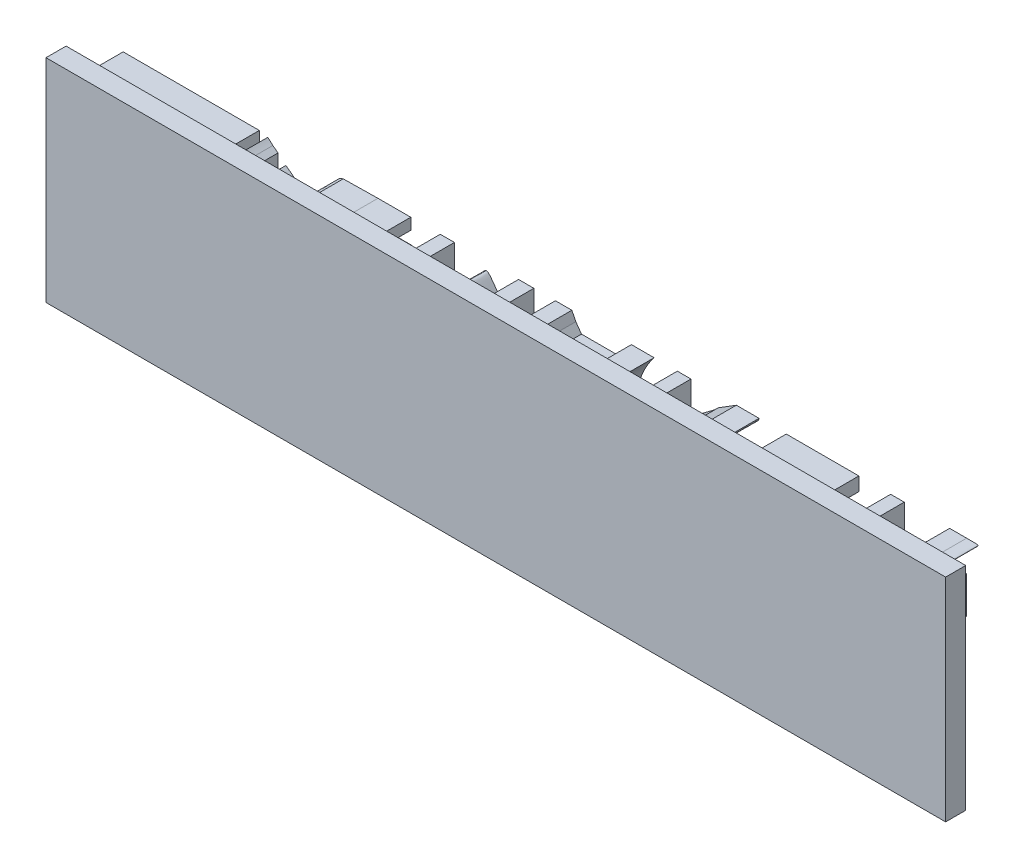
from build123d import *

# Parameters (mm, degrees)
BOSS_EXTRUDE1_DEPTH   = 20
BOSS_EXTRUDE1_2_DEPTH = 20
BOSS_EXTRUDE1_3_DEPTH = 20
BOSS_EXTRUDE1_4_DEPTH = 20
BOSS_EXTRUDE1_5_DEPTH = 20
BOSS_EXTRUDE1_6_DEPTH = 20
BOSS_EXTRUDE1_7_DEPTH = 20
BOSS_EXTRUDE1_8_DEPTH = 20
BOSS_EXTRUDE1_9_DEPTH = 20
SKETCH2_W             = 447.597863746
SKETCH2_H             = 105.500872559
BOSS_EXTRUDE2_DEPTH   = 10


with BuildPart() as part:
    # Sketch1 → Boss-Extrude1 (new body)
    with BuildSketch(Plane.XY):
        with BuildLine():
            Line((5.334, 288.459333), (5.051778, 287.330444))
            Line((5.051778, 287.330444), (5.051778, 276.606))
            Line((5.051778, 276.606), (5.051778, 266.417778))
            Line((5.051778, 266.417778), (5.334, 265.006667))
            add(Edge.make_bspline(
                [(5.334, 265.006667), (6.180667, 263.595556), (6.462889, 263.313333), (7.591778, 263.031111)],
                knots=[0, 0, 0, 0, 1, 1, 1, 1], degree=3))
            Line((7.591778, 263.031111), (8.720667, 262.466667))
            Line((8.720667, 262.466667), (23.734889, 262.466667))
            Line((23.734889, 262.466667), (38.664444, 262.466667))
            Line((38.664444, 262.466667), (39.793333, 263.031111))
            add(Edge.make_bspline(
                [(39.793333, 263.031111), (40.922222, 263.313333), (41.204444, 263.877778), (41.486667, 264.724444)],
                knots=[0, 0, 0, 0, 1, 1, 1, 1], degree=3))
            add(Edge.make_bspline(
                [(41.486667, 264.724444), (42.051111, 265.571111), (42.333333, 265.853333), (42.333333, 272.654889)],
                knots=[0, 0, 0, 0, 1, 1, 1, 1], degree=3))
            Line((42.333333, 272.654889), (42.333333, 279.428222))
            Line((42.333333, 279.428222), (27.149778, 279.428222))
            Line((27.149778, 279.428222), (11.994444, 279.428222))
            Line((11.994444, 279.428222), (11.994444, 282.532667))
            Line((11.994444, 282.532667), (11.994444, 285.637111))
            Line((11.994444, 285.637111), (27.149778, 285.637111))
            Line((27.149778, 285.637111), (42.333333, 285.637111))
            Line((42.333333, 285.637111), (42.333333, 288.459333))
            Line((42.333333, 288.459333), (42.333333, 291.281556))
            Line((42.333333, 291.281556), (26.020889, 291.281556))
            add(Edge.make_bspline(
                [(26.020889, 291.281556), (16.961556, 291.281556), (9.285111, 290.999333), (8.720667, 290.999333)],
                knots=[0, 0, 0, 0, 1, 1, 1, 1], degree=3))
            add(Edge.make_bspline(
                [(8.720667, 290.999333), (7.027333, 290.434889), (6.180667, 289.870444), (5.334, 288.459333)],
                knots=[0, 0, 0, 0, 1, 1, 1, 1], degree=3))
        make_face()
        with BuildLine():
            Line((35.277778, 270.679333), (35.277778, 267.546667))
            Line((35.277778, 267.546667), (23.509111, 267.546667))
            Line((23.509111, 267.546667), (11.994444, 267.546667))
            Line((11.994444, 267.546667), (11.768667, 270.397111))
            add(Edge.make_bspline(
                [(11.768667, 270.397111), (11.768667, 272.090444), (11.768667, 273.219333), (11.768667, 273.501556)],
                knots=[0, 0, 0, 0, 1, 1, 1, 1], degree=3))
            add(Edge.make_bspline(
                [(11.768667, 273.501556), (11.994444, 273.783778), (14.252222, 273.783778), (23.509111, 273.783778)],
                knots=[0, 0, 0, 0, 1, 1, 1, 1], degree=3))
            Line((23.509111, 273.783778), (35.277778, 273.783778))
            Line((35.277778, 273.783778), (35.277778, 270.679333))
        make_face(mode=Mode.SUBTRACT)
    extrude(amount=-BOSS_EXTRUDE1_DEPTH)



with BuildPart() as body_2:
    # Sketch1 → Boss-Extrude1 2 (new body)
    with BuildSketch(Plane.XY):
        with BuildLine():
            Line((57.008889, 273.501556), (57.008889, 255.693333))
            Line((57.008889, 255.693333), (60.677778, 255.693333))
            Line((60.677778, 255.693333), (64.064444, 255.693333))
            Line((64.064444, 255.693333), (72.248889, 266.417778))
            add(Edge.make_bspline(
                [(72.248889, 266.417778), (76.764444, 272.090444), (80.715556, 277.170444), (80.715556, 276.888222)],
                knots=[0, 0, 0, 0, 1, 1, 1, 1], degree=3))
            add(Edge.make_bspline(
                [(80.715556, 276.888222), (84.384444, 272.090444), (88.9, 266.417778)],
                knots=[0, 0, 0, 1, 1, 1], degree=2))
            Line((88.9, 266.417778), (96.802222, 255.693333))
            Line((96.802222, 255.693333), (100.188889, 255.693333))
            Line((100.188889, 255.693333), (103.575556, 255.693333))
            Line((103.575556, 255.693333), (103.575556, 273.501556))
            Line((103.575556, 273.501556), (103.575556, 291.281556))
            Line((103.575556, 291.281556), (99.906667, 291.281556))
            Line((99.906667, 291.281556), (95.955556, 291.281556))
            Line((95.955556, 291.281556), (95.955556, 278.581556))
            Line((95.955556, 278.581556), (96.237778, 265.853333))
            Line((96.237778, 265.853333), (95.391111, 267.264444))
            add(Edge.make_bspline(
                [(95.391111, 267.264444), (94.826667, 268.139333), (91.44, 272.937111), (87.771111, 277.734889)],
                knots=[0, 0, 0, 0, 1, 1, 1, 1], degree=3))
            add(Edge.make_bspline(
                [(87.771111, 277.734889), (80.997778, 287.048222), (80.997778, 287.048222), (79.868889, 287.048222)],
                knots=[0, 0, 0, 0, 1, 1, 1, 1], degree=3))
            add(Edge.make_bspline(
                [(79.868889, 287.048222), (79.304444, 287.048222), (79.022222, 287.048222), (72.531111, 278.017111)],
                knots=[0, 0, 0, 0, 1, 1, 1, 1], degree=3))
            add(Edge.make_bspline(
                [(72.531111, 278.017111), (68.58, 273.219333), (65.193333, 268.421556), (64.911111, 267.546667)],
                knots=[0, 0, 0, 0, 1, 1, 1, 1], degree=3))
            add(Edge.make_bspline(
                [(64.911111, 267.546667), (64.346667, 266.7), (64.064444, 266.417778), (64.064444, 266.135556)],
                knots=[0, 0, 0, 0, 1, 1, 1, 1], degree=3))
            add(Edge.make_bspline(
                [(64.064444, 266.135556), (64.064444, 271.808222), (64.064444, 278.863778)],
                knots=[0, 0, 0, 1, 1, 1], degree=2))
            Line((64.064444, 278.863778), (64.064444, 291.281556))
            Line((64.064444, 291.281556), (60.677778, 291.281556))
            Line((60.677778, 291.281556), (57.008889, 291.281556))
            Line((57.008889, 291.281556), (57.008889, 273.501556))
        make_face()
    extrude(amount=-BOSS_EXTRUDE1_2_DEPTH)


with BuildPart() as body_3:
    # Sketch1 → Boss-Extrude1 3 (new body)
    with BuildSketch(Plane.XY):
        with BuildLine():
            Line((124.177778, 273.219333), (134.055556, 255.693333))
            Line((134.055556, 255.693333), (138.571111, 255.693333))
            Line((138.571111, 255.693333), (143.086667, 255.693333))
            Line((143.086667, 255.693333), (145.344444, 261.62))
            add(Edge.make_bspline(
                [(145.344444, 261.62), (147.602222, 265.006667), (152.117778, 272.937111), (156.633333, 279.146)],
                knots=[0, 0, 0, 0, 1, 1, 1, 1], degree=3))
            add(Edge.make_bspline(
                [(156.633333, 279.146), (158.891111, 285.637111), (163.406667, 291.281556)],
                knots=[0, 0, 0, 1, 1, 1], degree=2))
            add(Edge.make_bspline(
                [(163.406667, 291.281556), (161.148889, 291.281556), (158.891111, 291.281556)],
                knots=[0, 0, 0, 1, 1, 1], degree=2))
            Line((158.891111, 291.281556), (152.117778, 291.281556))
            Line((152.117778, 291.281556), (152.117778, 287.330444))
            Line((152.117778, 287.330444), (149.86, 283.379333))
            Line((149.86, 283.379333), (138.571111, 283.379333))
            Line((138.571111, 283.379333), (127.282222, 283.379333))
            Line((127.282222, 283.379333), (124.46, 287.330444))
            Line((124.46, 287.330444), (122.484444, 291.281556))
            Line((122.484444, 291.281556), (118.251111, 291.281556))
            add(Edge.make_bspline(
                [(118.251111, 291.281556), (115.993333, 291.281556), (114.3, 291.281556)],
                knots=[0, 0, 0, 1, 1, 1], degree=2))
            add(Edge.make_bspline(
                [(114.3, 291.281556), (114.3, 290.999333), (118.815556, 283.097111), (124.177778, 273.219333)],
                knots=[0, 0, 0, 0, 1, 1, 1, 1], degree=3))
        make_face()
        with BuildLine():
            Line((145.344444, 276.888222), (138.571111, 262.748889))
            add(Edge.make_bspline(
                [(138.571111, 262.748889), (138.571111, 263.031111), (129.54, 276.888222), (129.54, 277.170444)],
                knots=[0, 0, 0, 0, 1, 1, 1, 1], degree=3))
            add(Edge.make_bspline(
                [(129.54, 277.170444), (134.055556, 277.170444), (138.571111, 277.170444)],
                knots=[0, 0, 0, 1, 1, 1], degree=2))
            add(Edge.make_bspline(
                [(138.571111, 277.170444), (143.086667, 277.170444), (145.344444, 277.170444), (145.344444, 276.888222)],
                knots=[0, 0, 0, 0, 1, 1, 1, 1], degree=3))
        make_face(mode=Mode.SUBTRACT)
    extrude(amount=-BOSS_EXTRUDE1_3_DEPTH)


with BuildPart() as body_4:
    # Sketch1 → Boss-Extrude1 4 (new body)
    with BuildSketch(Plane.XY):
        with BuildLine():
            Line((174.977778, 273.501556), (174.977778, 255.693333))
            Line((174.977778, 255.693333), (177.235556, 255.693333))
            Line((177.235556, 255.693333), (181.751111, 255.693333))
            Line((181.751111, 255.693333), (181.751111, 263.031111))
            Line((181.751111, 263.031111), (181.751111, 270.397111))
            Line((181.751111, 270.397111), (193.04, 263.031111))
            Line((193.04, 263.031111), (202.071111, 255.693333))
            Line((202.071111, 255.693333), (208.844444, 255.693333))
            Line((208.844444, 255.693333), (213.36, 255.975556))
            Line((213.36, 255.975556), (202.071111, 264.16))
            add(Edge.make_bspline(
                [(202.071111, 264.16), (195.297778, 268.703778), (190.782222, 272.372667)],
                knots=[0, 0, 0, 1, 1, 1], degree=2))
            add(Edge.make_bspline(
                [(190.782222, 272.372667), (190.782222, 272.654889), (202.071111, 280.557111), (211.102222, 287.612667)],
                knots=[0, 0, 0, 0, 1, 1, 1, 1], degree=3))
            add(Edge.make_bspline(
                [(211.102222, 287.612667), (215.617778, 289.306), (215.617778, 290.999333), (215.617778, 291.281556)],
                knots=[0, 0, 0, 0, 1, 1, 1, 1], degree=3))
            add(Edge.make_bspline(
                [(215.617778, 291.281556), (213.36, 291.281556), (211.102222, 291.281556)],
                knots=[0, 0, 0, 1, 1, 1], degree=2))
            Line((211.102222, 291.281556), (204.328889, 291.281556))
            Line((204.328889, 291.281556), (195.297778, 285.637111))
            add(Edge.make_bspline(
                [(195.297778, 285.637111), (193.04, 282.814889), (186.266667, 279.146), (186.266667, 278.017111)],
                knots=[0, 0, 0, 0, 1, 1, 1, 1], degree=3))
            Line((186.266667, 278.017111), (181.751111, 275.759333))
            Line((181.751111, 275.759333), (181.751111, 283.379333))
            Line((181.751111, 283.379333), (181.751111, 291.281556))
            Line((181.751111, 291.281556), (177.235556, 291.281556))
            Line((177.235556, 291.281556), (174.977778, 291.281556))
            Line((174.977778, 291.281556), (174.977778, 273.501556))
        make_face()
    extrude(amount=-BOSS_EXTRUDE1_4_DEPTH)


with BuildPart() as body_5:
    # Sketch1 → Boss-Extrude1 5 (new body)
    with BuildSketch(Plane.XY):
        Polygon((229.164444, 273.501556), (229.164444, 255.693333), (247.226667, 255.693333), (265.288889, 255.693333), (265.288889, 258.797778), (265.288889, 261.902222), (251.742222, 261.902222), (235.937778, 261.902222), (235.937778, 265.853333), (235.937778, 269.832667), (244.968889, 269.832667), (254, 269.832667), (254, 272.937111), (254, 275.759333), (244.968889, 275.759333), (235.937778, 275.759333), (235.937778, 280.274889), (235.937778, 284.508222), (251.742222, 284.508222), (265.288889, 284.508222), (265.288889, 287.894889), (265.288889, 291.281556), (247.226667, 291.281556), (229.164444, 291.281556), align=None)
    extrude(amount=-BOSS_EXTRUDE1_5_DEPTH)


with BuildPart() as body_6:
    # Sketch1 → Boss-Extrude1 6 (new body)
    with BuildSketch(Plane.XY):
        with BuildLine():
            Line((281.093333, 273.219333), (281.093333, 255.693333))
            Line((281.093333, 255.693333), (296.333333, 255.693333))
            add(Edge.make_bspline(
                [(296.333333, 255.693333), (316.088889, 255.975556), (316.088889, 255.693333), (318.911111, 257.668889)],
                knots=[0, 0, 0, 0, 1, 1, 1, 1], degree=3))
            add(Edge.make_bspline(
                [(318.911111, 257.668889), (318.911111, 259.08), (318.911111, 259.926667), (318.911111, 267.546667)],
                knots=[0, 0, 0, 0, 1, 1, 1, 1], degree=3))
            add(Edge.make_bspline(
                [(318.911111, 267.546667), (318.911111, 274.348222), (318.911111, 274.348222), (318.911111, 275.759333)],
                knots=[0, 0, 0, 0, 1, 1, 1, 1], degree=3))
            add(Edge.make_bspline(
                [(318.911111, 275.759333), (316.088889, 277.452667), (316.088889, 277.734889), (310.444444, 277.734889)],
                knots=[0, 0, 0, 0, 1, 1, 1, 1], degree=3))
            Line((310.444444, 277.734889), (304.8, 278.017111))
            Line((304.8, 278.017111), (316.088889, 284.226))
            add(Edge.make_bspline(
                [(316.088889, 284.226), (318.911111, 287.612667), (324.555556, 290.434889), (324.555556, 290.717111)],
                knots=[0, 0, 0, 0, 1, 1, 1, 1], degree=3))
            add(Edge.make_bspline(
                [(324.555556, 290.717111), (324.555556, 291.281556), (324.555556, 291.281556), (318.911111, 291.281556)],
                knots=[0, 0, 0, 0, 1, 1, 1, 1], degree=3))
            Line((318.911111, 291.281556), (310.444444, 291.281556))
            Line((310.444444, 291.281556), (304.8, 284.508222))
            Line((304.8, 284.508222), (296.333333, 277.734889))
            Line((296.333333, 277.734889), (293.511111, 277.734889))
            Line((293.511111, 277.734889), (287.866667, 278.017111))
            Line((287.866667, 278.017111), (287.866667, 284.508222))
            Line((287.866667, 284.508222), (287.866667, 291.281556))
            Line((287.866667, 291.281556), (285.044444, 291.281556))
            Line((285.044444, 291.281556), (281.093333, 291.281556))
            Line((281.093333, 291.281556), (281.093333, 273.219333))
        make_face()
        with BuildLine():
            Line((299.155556, 261.902222), (287.866667, 261.902222))
            Line((287.866667, 261.902222), (287.866667, 266.7))
            Line((287.866667, 266.7), (287.866667, 271.808222))
            Line((287.866667, 271.808222), (299.155556, 271.808222))
            Line((299.155556, 271.808222), (310.444444, 271.808222))
            Line((310.444444, 271.808222), (310.444444, 270.961556))
            add(Edge.make_bspline(
                [(310.444444, 270.961556), (310.444444, 270.397111), (310.444444, 270.397111), (310.444444, 267.264444)],
                knots=[0, 0, 0, 0, 1, 1, 1, 1], degree=3))
            add(Edge.make_bspline(
                [(310.444444, 267.264444), (310.444444, 263.595556), (310.444444, 263.031111), (310.444444, 262.184444)],
                knots=[0, 0, 0, 0, 1, 1, 1, 1], degree=3))
            add(Edge.make_bspline(
                [(310.444444, 262.184444), (307.622222, 261.902222), (307.622222, 261.902222), (299.155556, 261.902222)],
                knots=[0, 0, 0, 0, 1, 1, 1, 1], degree=3))
        make_face(mode=Mode.SUBTRACT)
    extrude(amount=-BOSS_EXTRUDE1_6_DEPTH)


with BuildPart() as body_7:
    # Sketch1 → Boss-Extrude1 7 (new body)
    with BuildSketch(Plane.XY):
        Polygon((-100.753333, 257.104444), (-100.753333, 223.237778), (-66.886667, 223.237778), (-33.02, 223.237778), (-33.02, 231.704444), (-33.02, 239.888889), (-56.444444, 239.888889), (-80.151111, 239.888889), (-80.151111, 245.251111), (-80.151111, 250.331111), (-56.444444, 250.331111), (-33.02, 250.331111), (-33.02, 257.951111), (-33.02, 265.288889), (-56.444444, 265.288889), (-80.151111, 265.288889), (-80.151111, 270.961556), (-80.151111, 276.041556), (-56.444444, 276.041556), (-33.02, 276.041556), (-33.02, 283.379333), (-33.02, 290.999333), (-66.886667, 290.999333), (-100.753333, 290.999333), align=None)
    extrude(amount=-BOSS_EXTRUDE1_7_DEPTH)


with BuildPart() as body_8:
    # Sketch1 → Boss-Extrude1 8 (new body)
    with BuildSketch(Plane.XY):
        with BuildLine():
            Line((-29.068889, 256.54), (-29.068889, 222.955556))
            Line((-29.068889, 222.955556), (-18.654889, 214.488889))
            add(Edge.make_bspline(
                [(-18.654889, 214.488889), (-12.728222, 209.973333), (-7.648222, 206.022222), (-7.366, 206.022222)],
                knots=[0, 0, 0, 0, 1, 1, 1, 1], degree=3))
            add(Edge.make_bspline(
                [(-7.366, 206.022222), (-7.083778, 205.74), (-7.083778, 206.586667), (-7.083778, 238.76)],
                knots=[0, 0, 0, 0, 1, 1, 1, 1], degree=3))
            Line((-7.083778, 238.76), (-7.083778, 272.090444))
            Line((-7.083778, 272.090444), (-8.777111, 273.783778))
            Line((-8.777111, 273.783778), (-10.752667, 275.477111))
            Line((-10.752667, 275.477111), (-10.752667, 252.024444))
            add(Edge.make_bspline(
                [(-10.752667, 252.024444), (-10.752667, 239.606667), (-10.752667, 229.164444), (-11.034889, 229.164444)],
                knots=[0, 0, 0, 0, 1, 1, 1, 1], degree=3))
            add(Edge.make_bspline(
                [(-11.034889, 229.164444), (-11.881556, 229.728889), (-13.010444, 230.857778)],
                knots=[0, 0, 0, 1, 1, 1], degree=2))
            Line((-13.010444, 230.857778), (-15.268222, 232.268889))
            Line((-15.268222, 232.268889), (-15.268222, 255.693333))
            Line((-15.268222, 255.693333), (-15.268222, 279.146))
            Line((-15.268222, 279.146), (-17.526, 280.839333))
            Line((-17.526, 280.839333), (-19.783778, 282.532667))
            Line((-19.783778, 282.532667), (-19.783778, 259.08))
            Line((-19.783778, 259.08), (-19.783778, 235.937778))
            Line((-19.783778, 235.937778), (-21.759333, 237.631111))
            Line((-21.759333, 237.631111), (-23.734889, 239.042222))
            Line((-23.734889, 239.042222), (-23.734889, 262.466667))
            Line((-23.734889, 262.466667), (-23.734889, 285.919333))
            Line((-23.734889, 285.919333), (-26.274889, 287.894889))
            add(Edge.make_bspline(
                [(-26.274889, 287.894889), (-27.686, 289.023778), (-28.786667, 290.152667)],
                knots=[0, 0, 0, 1, 1, 1], degree=2))
            add(Edge.make_bspline(
                [(-28.786667, 290.152667), (-29.068889, 290.152667), (-29.068889, 283.379333), (-29.068889, 256.54)],
                knots=[0, 0, 0, 0, 1, 1, 1, 1], degree=3))
        make_face()
    extrude(amount=-BOSS_EXTRUDE1_8_DEPTH)


with BuildPart() as body_9:
    # Sketch1 → Boss-Extrude1 9 (new body)
    with BuildSketch(Plane.XY):
        Polygon((-86.077778, 211.948889), (-73.095556, 203.2), (-41.204444, 203.2), (-9.059333, 203.2), (-11.881556, 205.457778), (-14.139333, 207.433333), (-36.688889, 207.433333), (-59.548889, 207.433333), (-61.242222, 208.844444), (-62.935556, 209.973333), (-40.64, 210.255556), (-18.090444, 210.255556), (-20.348222, 212.231111), (-22.888222, 213.924444), (-45.72, 213.924444), (-68.58, 213.924444), (-70.837778, 215.335556), (-72.531111, 216.746667), (-49.388889, 216.746667), (-26.557111, 216.746667), (-28.786667, 218.722222), (-31.044444, 220.697778), (-65.193333, 220.697778), (-99.06, 220.697778), align=None)
    extrude(amount=-BOSS_EXTRUDE1_9_DEPTH)


with BuildPart() as part_1:
    add(part.part)

    add(body_2.part)  # Boss-Extrude2 merges body 2

    add(body_3.part)  # Boss-Extrude2 merges body 3

    add(body_4.part)  # Boss-Extrude2 merges body 4

    add(body_5.part)  # Boss-Extrude2 merges body 5

    add(body_6.part)  # Boss-Extrude2 merges body 6

    add(body_7.part)  # Boss-Extrude2 merges body 7

    add(body_8.part)  # Boss-Extrude2 merges body 8

    add(body_9.part)  # Boss-Extrude2 merges body 9
    # Sketch2 → Boss-Extrude2 (add)
    with BuildSketch(Plane.XY):
        with Locations((114.64877264, 246.532737655)):
            Rectangle(SKETCH2_W, SKETCH2_H)
    extrude(amount=BOSS_EXTRUDE2_DEPTH)


solid = part_1.part
